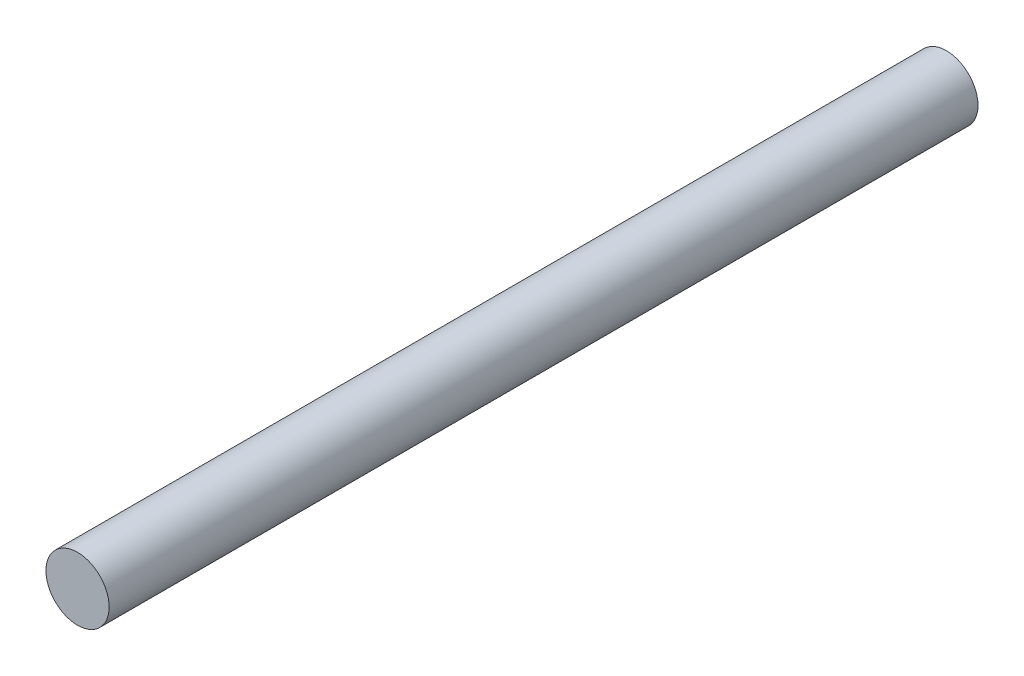
from build123d import *

# Parameters (mm, degrees)
SKETCH1_R           = 4
BOSS_EXTRUDE1_DEPTH = 110


with BuildPart() as part:
    # Sketch1 → Boss-Extrude1 (new body)
    with BuildSketch(Plane.XY):
        Circle(SKETCH1_R)
    extrude(amount=BOSS_EXTRUDE1_DEPTH)


solid = part.part
